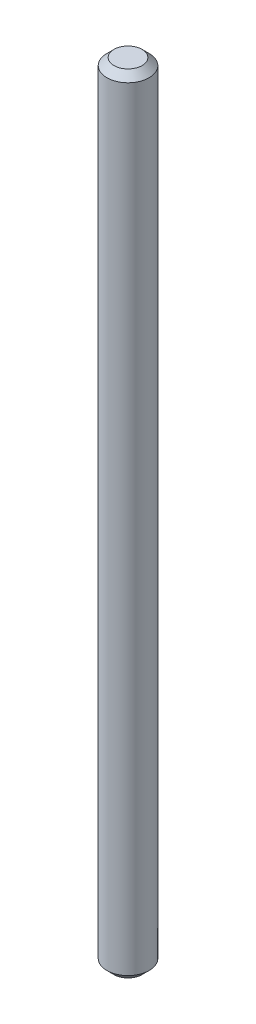
from build123d import *


with BuildPart() as part:
    # Sketch1 → Revolve1 (revolve)
    with BuildSketch(Plane.XY, mode=Mode.PRIVATE) as revolve1_sk:
        Polygon((1, 5), (1.5, 4.5), (1.5, -50.5), (1, -51), (0, -51), (0, 5), align=None)
    revolve(revolve1_sk.sketch.rotate(Axis((0, 5, 0), (0, 1, 0)), 90), axis=Axis((0, 5, 0), (0, 1, 0)))  # turned: the seam where the file's is


solid = part.part
